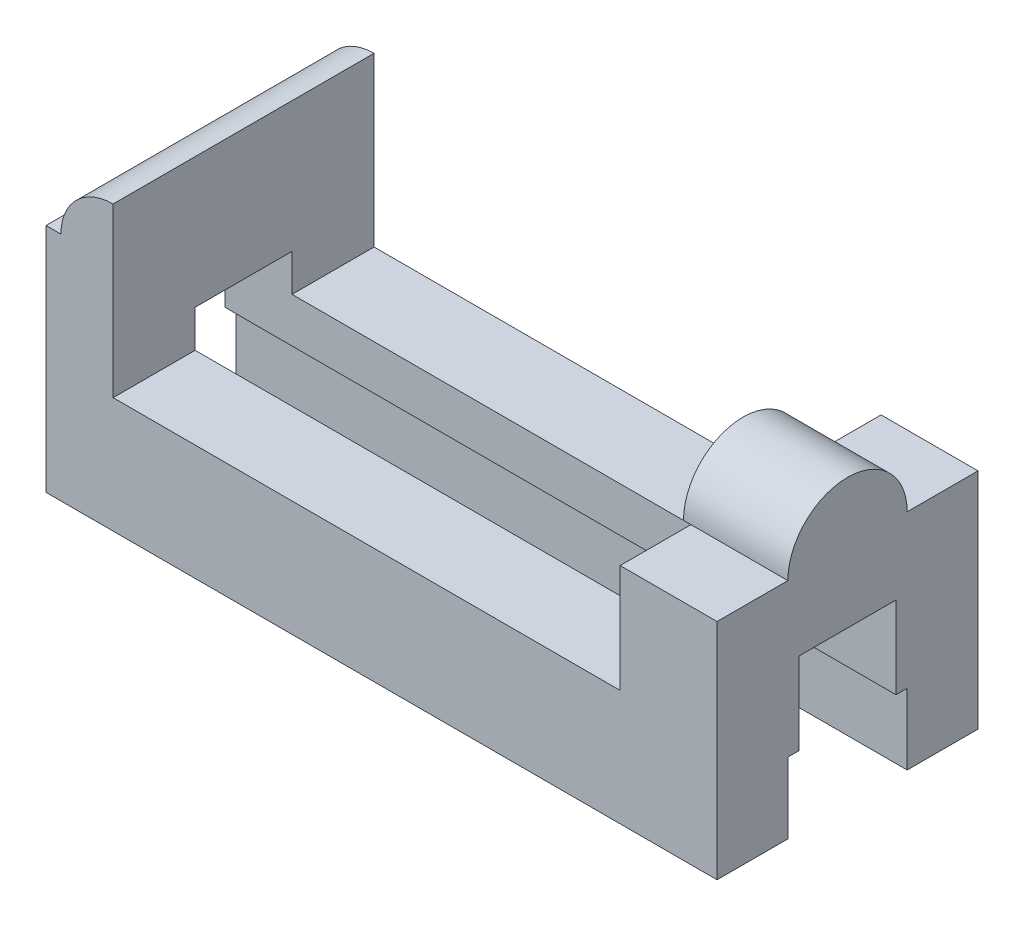
from build123d import *

# Parameters (mm, degrees)
BOSS_EXTRUDE1_DEPTH     = 35
CUT_EXTRUDE1_DEPTH      = 1
CUT_EXTRUDE1_DEPTH_BACK = 181
CUT_EXTRUDE2_DEPTH      = 70
SKETCH9_W               = 70
SKETCH9_H               = 16
CUT_EXTRUDE4_DEPTH      = 70
BOSS_EXTRUDE2_DEPTH     = 28


with BuildPart() as part:
    # Sketch2 → Boss-Extrude1 (new body, symmetric)
    with BuildSketch(Plane.XY):
        Polygon((-72, 38), (-72, -7), (64, -7), (64, 38), (90, 38), (90, -38), (-90, -38), (-90, 38), align=None)
    extrude(amount=BOSS_EXTRUDE1_DEPTH, both=True)

    # Sketch3 → Cut-Extrude1 (cut, two sides)
    with BuildSketch(Plane(origin=(90, 0, 0), x_dir=(0, 0, -1), z_dir=(1, 0, 0))) as cut_extrude1_sk:
        Polygon((16, -38), (16, -19), (13, -19), (13, 3), (-13, 3), (-13, -19), (-16, -19), (-16, -38), align=None)
    extrude(amount=CUT_EXTRUDE1_DEPTH, mode=Mode.SUBTRACT)
    extrude(cut_extrude1_sk.sketch, amount=-CUT_EXTRUDE1_DEPTH_BACK, mode=Mode.SUBTRACT)

    # Sketch5 → Cut-Extrude2 (cut)
    with BuildSketch(Plane.XY.offset(35)):
        with BuildLine():
            Line((-90, 24), (-86, 24))
            ThreePointArc((-86, 24), (-81.899494937, 33.899494937), (-72, 38))
            Line((-72, 38), (-90, 38))
            Line((-90, 38), (-90, 24))
        make_face()
    extrude(amount=-CUT_EXTRUDE2_DEPTH, mode=Mode.SUBTRACT)

    # Sketch9 → Cut-Extrude4 (cut)
    with BuildSketch(Plane(origin=(90, 0, 0), x_dir=(0, 0, -1), z_dir=(1, 0, 0))):
        with Locations((0, 30)):
            Rectangle(SKETCH9_W, SKETCH9_H)
    extrude(amount=-CUT_EXTRUDE4_DEPTH, mode=Mode.SUBTRACT)

    # Sketch10 → Boss-Extrude2 (add)
    with BuildSketch(Plane(origin=(90, 0, 0), x_dir=(0, 0, -1), z_dir=(1, 0, 0))):
        with BuildLine():
            Line((-16, 22), (16, 22))
            ThreePointArc((16, 22), (0, 38), (-16, 22))
        make_face()
    extrude(amount=-BOSS_EXTRUDE2_DEPTH)


solid = part.part
